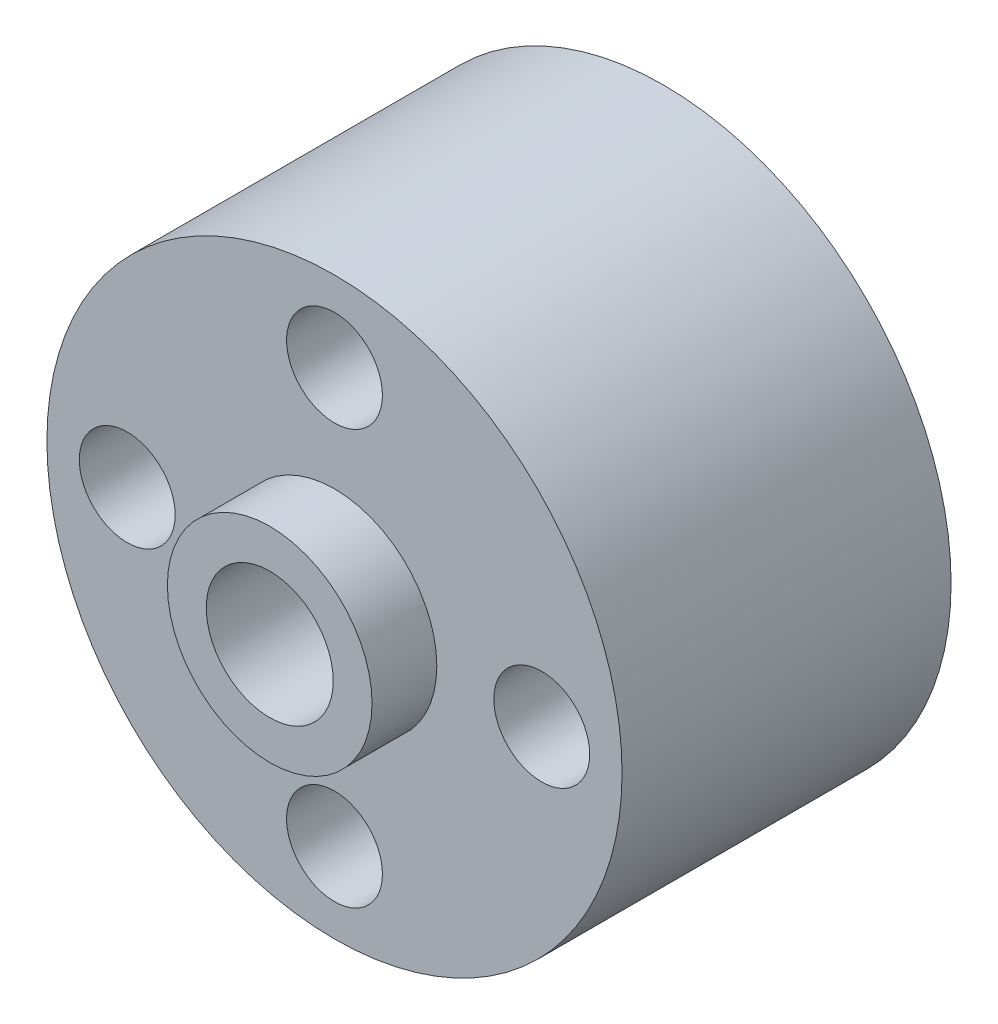
from build123d import *

# Parameters (mm, degrees)
SKETCH1_R          = 11.1
EXTRUDE1_DEPTH     = 12.7
SKETCH3_R          = 1.85
CUT_EXTRUDE1_DEPTH = 13.7
SKETCH6_R          = 3.95
EXTRUDE3_DEPTH     = 2.5
SKETCH7_R          = 3.95
EXTRUDE4_DEPTH     = 2.5
SKETCH8_R          = 2.45
CUT_EXTRUDE2_DEPTH = 18.7


with BuildPart() as part:
    # Sketch1 → Extrude1 (new body)
    with BuildSketch(Plane.XY):
        Circle(SKETCH1_R)
    extrude(amount=-EXTRUDE1_DEPTH)

    # Sketch3 → Cut-Extrude1 (cut, through all)
    with BuildSketch(Plane.XY):
        with Locations((8, 0)):
            Circle(SKETCH3_R)
        with Locations((-8, 0)):
            Circle(SKETCH3_R)
        with Locations((0, -8)):
            Circle(SKETCH3_R)
        with Locations((0, 8)):
            Circle(SKETCH3_R)
    extrude(amount=-CUT_EXTRUDE1_DEPTH, mode=Mode.SUBTRACT)

    # Sketch6 → Extrude3 (add)
    with BuildSketch(Plane.XY):
        Circle(SKETCH6_R)
    extrude(amount=EXTRUDE3_DEPTH)

    # Sketch7 → Extrude4 (add)
    with BuildSketch(Plane(origin=(0, 0, -12.7), x_dir=(-1, 0, 0), z_dir=(0, 0, -1))):
        Circle(SKETCH7_R)
    extrude(amount=EXTRUDE4_DEPTH)

    # Sketch8 → Cut-Extrude2 (cut, through all)
    with BuildSketch(Plane.XY.offset(2.5)):
        Circle(SKETCH8_R)
    extrude(amount=-CUT_EXTRUDE2_DEPTH, mode=Mode.SUBTRACT)


solid = part.part
